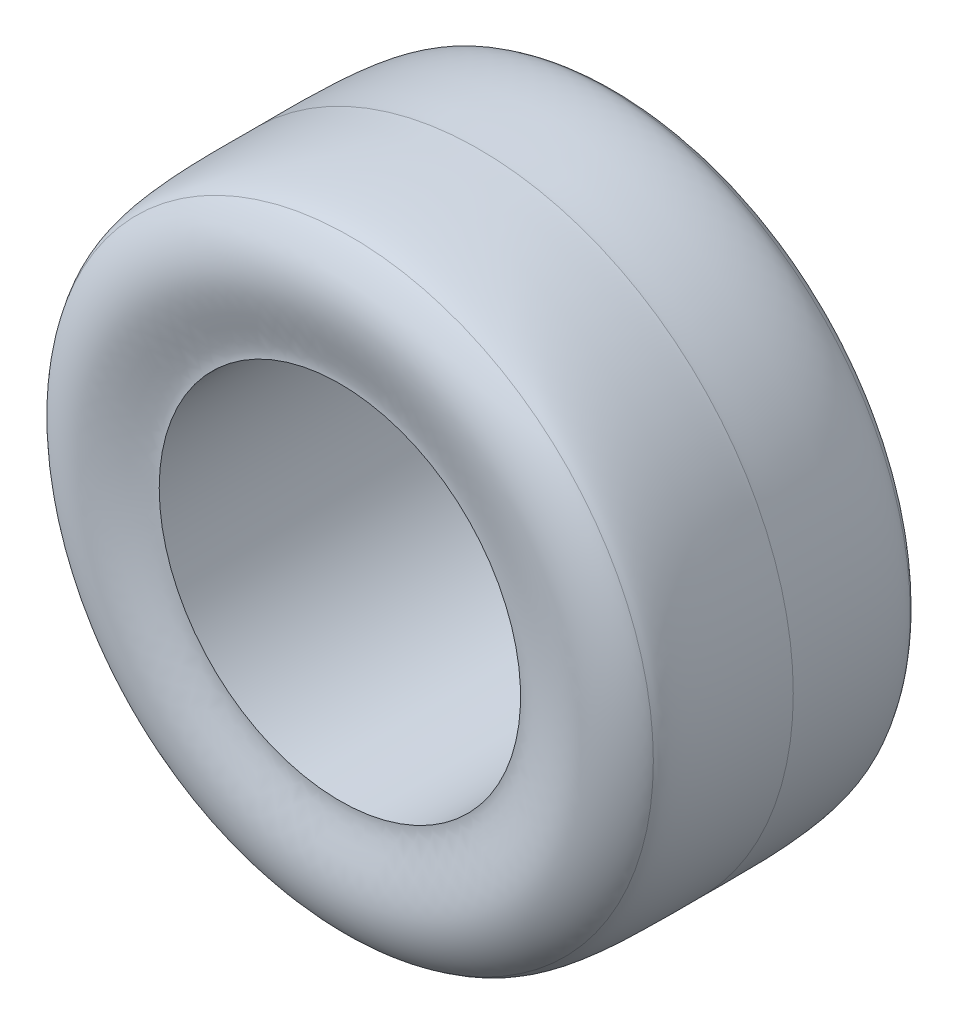
from build123d import *


with BuildPart() as part:
    # Sketch1 → Revolve1 (revolve)
    with BuildSketch(Plane(origin=(0, 0, 0), x_dir=(0, 0, -1), z_dir=(1, 0, 0))):
        with BuildLine():
            Line((-117.286167083, 276.507310694), (117.286167083, 276.507310694))
            add(Edge.make_bspline(
                [(0, 287), (4.079279904, 286.826687196), (106.061876701, 288.284046759), (113.606283575, 278.880093182), (117.286167083, 276.507310694)],
                knots=[0, 0, 0, 0, 0.064751478, 0.299257628, 0.299257628, 0.299257628, 0.299257628], degree=3))
            add(Edge.make_bspline(
                [(0, 287), (-4.079279904, 286.826687196), (-106.061876701, 288.284046759), (-113.606283575, 278.880093182), (-117.286167083, 276.507310694)],
                knots=[0, 0, 0, 0, 0.064751478, 0.299257628, 0.299257628, 0.299257628, 0.299257628], degree=3))
        make_face()
    revolve(axis=Axis((0, 0, 146.251356054), (0, 0, -1)))


with BuildPart() as body_2:
    # Sketch7 → Revolve2 (revolve)
    with BuildSketch(Plane(origin=(0, 0, 0), x_dir=(0, 0, -1), z_dir=(1, 0, 0))):
        with BuildLine():
            Line((-117.286167083, 276.507310694), (117.286167083, 276.507310694))
            add(Edge.make_bspline(
                [(117.286167083, 276.507310694), (117.526059044, 276.352628775), (123.196173432, 273.03306649), (155.207133321, 236.210615055), (126.01944742, 177.98197113), (127, 165)],
                knots=[0.299257628, 0.299257628, 0.299257628, 0.299257628, 0.314545107, 0.697277584, 1, 1, 1, 1], degree=3))
            Line((127, 165), (-127, 165))
            add(Edge.make_bspline(
                [(-117.286167083, 276.507310694), (-117.526059044, 276.352628775), (-123.196173432, 273.03306649), (-155.207133321, 236.210615055), (-126.01944742, 177.98197113), (-127, 165)],
                knots=[0.299257628, 0.299257628, 0.299257628, 0.299257628, 0.314545107, 0.697277584, 1, 1, 1, 1], degree=3))
        make_face()
    revolve(axis=Axis((0, 0, -194.897474353), (0, 0, 1)))


solid = Compound([part.part, body_2.part])
